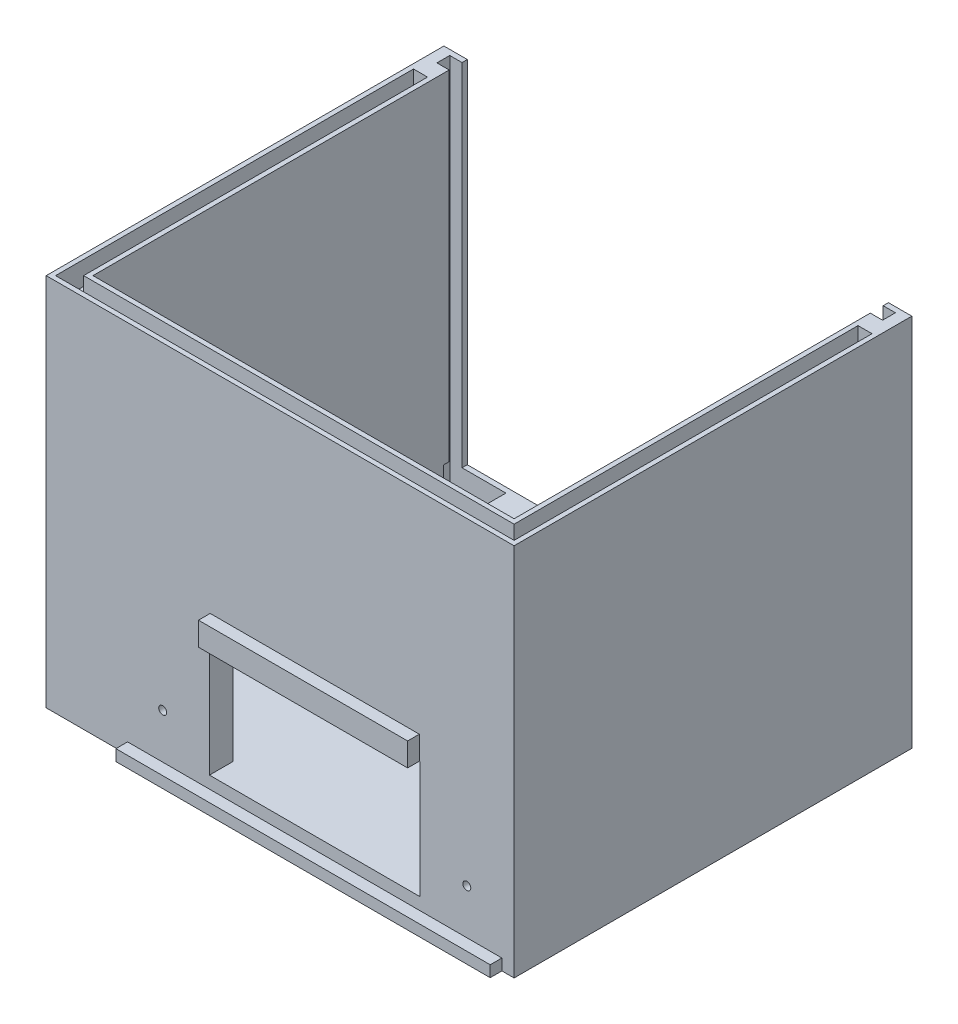
from build123d import *

# Parameters (mm, degrees)
CROQUIS1_W              = 200
CROQUIS1_H              = 170
SALIENTE_EXTRUIR1_DEPTH = 10
SALIENTE_EXTRUIR2_DEPTH = 150
CROQUIS3_W              = 90
CROQUIS3_H              = 10
SALIENTE_EXTRUIR3_DEPTH = 100
CROQUIS4_W              = 5.25
CROQUIS4_H              = 5.5
CORTAR_EXTRUIR1_DEPTH   = 170
CROQUIS7_W              = 90
CROQUIS7_H              = 10
SALIENTE_EXTRUIR4_DEPTH = 5
CORTAR_EXTRUIR3_DEPTH   = 10
CORTAR_EXTRUIR4_DEPTH   = 30
CORTAR_EXTRUIR5_DEPTH   = 5
CROQUIS10_W             = 30
CROQUIS10_H             = 13.5
CROQUIS10_W_2           = 24
CROQUIS10_H_2           = 8
SALIENTE_EXTRUIR5_DEPTH = 4.3
CROQUIS11_R             = 1.1
CORTAR_EXTRUIR6_DEPTH   = 14.3
CROQUIS12_R             = 1.75
CORTAR_EXTRUIR7_DEPTH   = 6.4
CROQUIS13_R             = 1.7
CORTAR_EXTRUIR8_DEPTH   = 5
CROQUIS14_W             = 0.3
CROQUIS14_H             = 10
CORTAR_EXTRUIR9_DEPTH   = 5
SALIENTE_EXTRUIR6_DEPTH = 5


with BuildPart() as part:
    # Croquis1 → Saliente-Extruir1 (new body)
    with BuildSketch(Plane(origin=(0, 0, 0), x_dir=(1, 0, 0), z_dir=(0, 1, 0))):
        Rectangle(CROQUIS1_W, CROQUIS1_H)
    extrude(amount=SALIENTE_EXTRUIR1_DEPTH)

    # Croquis2 → Saliente-Extruir2 (add)
    with BuildSketch(Plane(origin=(0, 10, 0), x_dir=(1, 0, 0), z_dir=(0, 1, 0))):
        Polygon((-100, 85), (-100, -85), (-30.21, -85), (-30.21, -75), (-90, -75), (-90, 85), align=None)
        Polygon((59.79, -75), (59.79, -85), (100, -85), (100, 85), (90, 85), (90, -75), align=None)
    extrude(amount=SALIENTE_EXTRUIR2_DEPTH)

    # Croquis3 → Saliente-Extruir3 (add)
    with BuildSketch(Plane(origin=(0, 160, 0), x_dir=(1, 0, 0), z_dir=(0, 1, 0))):
        with Locations((14.79, -80)):
            Rectangle(CROQUIS3_W, CROQUIS3_H)
    extrude(amount=-SALIENTE_EXTRUIR3_DEPTH)

    # Croquis4 → Cortar-Extruir1 (cut)
    with BuildSketch(Plane(origin=(0, 10, 65), x_dir=(-1, 0, 0), z_dir=(0, 1, 0))):
        with Locations((92.625, -145)):
            Rectangle(CROQUIS4_W, CROQUIS4_H)
        with Locations((-92.625, -145)):
            Rectangle(CROQUIS4_W, CROQUIS4_H)
    extrude(amount=CORTAR_EXTRUIR1_DEPTH, mode=Mode.SUBTRACT)

    # Croquis7 → Saliente-Extruir4 (add)
    with BuildSketch(Plane.XY.offset(85)):
        with Locations((14.79, 65)):
            Rectangle(CROQUIS7_W, CROQUIS7_H)
    extrude(amount=SALIENTE_EXTRUIR4_DEPTH)

    # Croquis8 → Cortar-Extruir3 (cut)
    with BuildSketch(Plane(origin=(0, 160, 0), x_dir=(1, 0, 0), z_dir=(0, 1, 0))):
        Polygon((98, -83), (98, 70), (92, 70), (92, -77), (-92, -77), (-92, 70), (-98, 70), (-98, -83), align=None)
    extrude(amount=-CORTAR_EXTRUIR3_DEPTH, mode=Mode.SUBTRACT)

    # Croquis9 → Cortar-Extruir4 (cut)
    with BuildSketch(Plane(origin=(0, 10, 0), x_dir=(1, 0, 0), z_dir=(0, 1, 0))):
        Polygon((-95.25, 77.25), (-95.25, 82.75), (-71.25, 82.75), (-71.25, 77.25), (-71.25, 74.75), (-95.25, 74.75), align=None)
    extrude(amount=-CORTAR_EXTRUIR4_DEPTH, mode=Mode.SUBTRACT)

    # Croquis9_2 → Cortar-Extruir5 (cut)
    with BuildSketch(Plane(origin=(0, 10, 0), x_dir=(1, 0, 0), z_dir=(0, 1, 0))):
        Polygon((-95.25, 77.25), (-95.25, 82.75), (-71.25, 82.75), (-71.25, 77.25), (-71.25, 74.75), (-95.25, 74.75), align=None)
    extrude(amount=CORTAR_EXTRUIR5_DEPTH, mode=Mode.SUBTRACT)

    # Croquis10 → Saliente-Extruir5 (add)
    with BuildSketch(Plane.XZ):
        with Locations((-83.25, -78.5)):
            Rectangle(CROQUIS10_W, CROQUIS10_H)
        with Locations((-83.25, -78.75)):
            Rectangle(CROQUIS10_W_2, CROQUIS10_H_2, mode=Mode.SUBTRACT)
    extrude(amount=SALIENTE_EXTRUIR5_DEPTH)

    # Croquis11 → Cortar-Extruir6 (cut)
    with BuildSketch(Plane.XY.offset(-71.75)):
        with Locations((-77.55, -2.1)):
            Circle(CROQUIS11_R)
        with Locations((-86.93, -2.1)):
            Circle(CROQUIS11_R)
    extrude(amount=-CORTAR_EXTRUIR6_DEPTH, mode=Mode.SUBTRACT)

    # Croquis12 → Cortar-Extruir7 (cut)
    with BuildSketch(Plane.XZ):
        with Locations((-91.5, -55)):
            Circle(CROQUIS12_R)
        with Locations((18.5, -55)):
            Circle(CROQUIS12_R)
        with Locations((-91.5, 55)):
            Circle(CROQUIS12_R)
        with Locations((18.5, 55)):
            Circle(CROQUIS12_R)
    extrude(amount=-CORTAR_EXTRUIR7_DEPTH, mode=Mode.SUBTRACT)

    # Croquis13 → Cortar-Extruir8 (cut)
    with BuildSketch(Plane.XY.offset(85)):
        with Locations((-50.21, 24)):
            Circle(CROQUIS13_R)
        with Locations((79.79, 24)):
            Circle(CROQUIS13_R)
    extrude(amount=-CORTAR_EXTRUIR8_DEPTH, mode=Mode.SUBTRACT)

    # Croquis14 → Cortar-Extruir9 (cut)
    with BuildSketch(Plane.XY.offset(90)):
        with Locations((-30.06, 65)):
            Rectangle(CROQUIS14_W, CROQUIS14_H)
        with Locations((59.64, 65)):
            Rectangle(CROQUIS14_W, CROQUIS14_H)
    extrude(amount=-CORTAR_EXTRUIR9_DEPTH, mode=Mode.SUBTRACT)

    # Croquis15 → Saliente-Extruir6 (add)
    with BuildSketch(Plane.XY.offset(85)):
        Polygon((14.79, 0), (94.79, 0), (94.79, 4.8), (14.79, 4.8), (-65.21, 4.8), (-65.21, 0), align=None)
    extrude(amount=SALIENTE_EXTRUIR6_DEPTH)


solid = part.part
